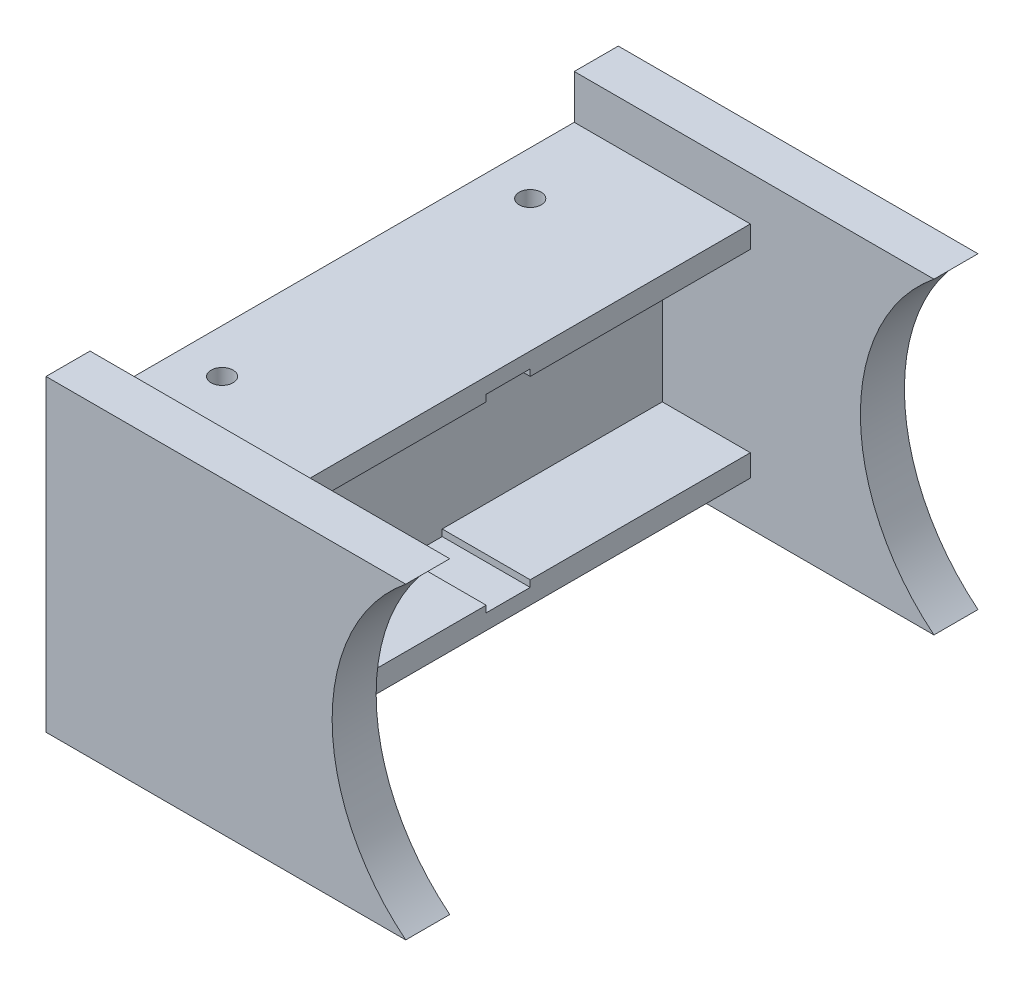
from build123d import *

# Parameters (mm, degrees)
BOSS_EXTRUDE1_DEPTH   = 12.7
BOSS_EXTRUDE1_2_DEPTH = 12.7
SKETCH1_3_W           = 69.85
SKETCH1_3_H           = 31.75
BOSS_EXTRUDE2_DEPTH   = 12.7
BOSS_EXTRUDE3_DEPTH   = 6.35
SKETCH4_R             = 1.5875
CUT_EXTRUDE1_DEPTH    = 20.32
SKETCH5_W             = 7.9375
SKETCH5_H             = 3.175
CUT_EXTRUDE2_DEPTH    = 12.7


with BuildPart() as part:
    # Sketch1 → Boss-Extrude1 (new body)
    with BuildSketch(Plane(origin=(0, 0, 0), x_dir=(0, 0, -1), z_dir=(1, 0, 0))):
        Polygon((3.175, -13.6525), (-3.175, -13.6525), (-3.175, -12.7), (-34.925, -12.7), (-34.925, -15.875), (34.925, -15.875), (34.925, -12.7), (3.175, -12.7), align=None)
    extrude(amount=BOSS_EXTRUDE1_DEPTH)



with BuildPart() as body_2:
    # Sketch1 → Boss-Extrude1 2 (new body)
    with BuildSketch(Plane(origin=(0, 0, 0), x_dir=(0, 0, -1), z_dir=(1, 0, 0))):
        Polygon((-34.925, 15.875), (-34.925, 12.7), (-3.175, 12.7), (-3.175, 13.6525), (3.175, 13.6525), (3.175, 12.7), (34.925, 12.7), (34.925, 15.875), align=None)
    extrude(amount=BOSS_EXTRUDE1_2_DEPTH)


with BuildPart() as part_1:
    add(part.part)

    add(body_2.part)  # Boss-Extrude2 merges body 2
    # Sketch1_3 → Boss-Extrude2 (add)
    with BuildSketch(Plane(origin=(0, 0, 0), x_dir=(0, 0, -1), z_dir=(1, 0, 0))):
        Rectangle(SKETCH1_3_W, SKETCH1_3_H)
    extrude(amount=-BOSS_EXTRUDE2_DEPTH)

    # Sketch3 → Boss-Extrude3 (add)
    with BuildSketch(Plane(origin=(0, 0, -34.925), x_dir=(-1, 0, 0), z_dir=(0, 0, -1))):
        with BuildLine():
            Line((-39.189487758, -22.225), (12.7, -22.225))
            Line((12.7, -22.225), (12.7, 22.225))
            Line((12.7, 22.225), (-39.189487758, 22.225))
            ThreePointArc((-39.189487758, 22.225), (-28.575, 0), (-39.189487758, -22.225))
        make_face()
    boss_extrude3 = extrude(amount=BOSS_EXTRUDE3_DEPTH)

    # Mirror1: Boss-Extrude3 across plane
    add(boss_extrude3.mirror(Plane.XY))

    # Sketch4 → Cut-Extrude1 (cut)
    with BuildSketch(Plane(origin=(0, 15.875, 0), x_dir=(1, 0, 0), z_dir=(0, 1, 0))):
        with Locations((-6.35, 22.225)):
            Circle(SKETCH4_R)
        with Locations((-6.35, -22.225)):
            Circle(SKETCH4_R)
    extrude(amount=-CUT_EXTRUDE1_DEPTH, mode=Mode.SUBTRACT)

    # Sketch5 → Cut-Extrude2 (cut)
    with BuildSketch(Plane.ZY.offset(12.7)):
        with Locations((-22.225, 4.7625)):
            Rectangle(SKETCH5_W, SKETCH5_H)
        with Locations((22.225, 4.7625)):
            Rectangle(SKETCH5_W, SKETCH5_H)
    extrude(amount=-CUT_EXTRUDE2_DEPTH, mode=Mode.SUBTRACT)


solid = part_1.part
